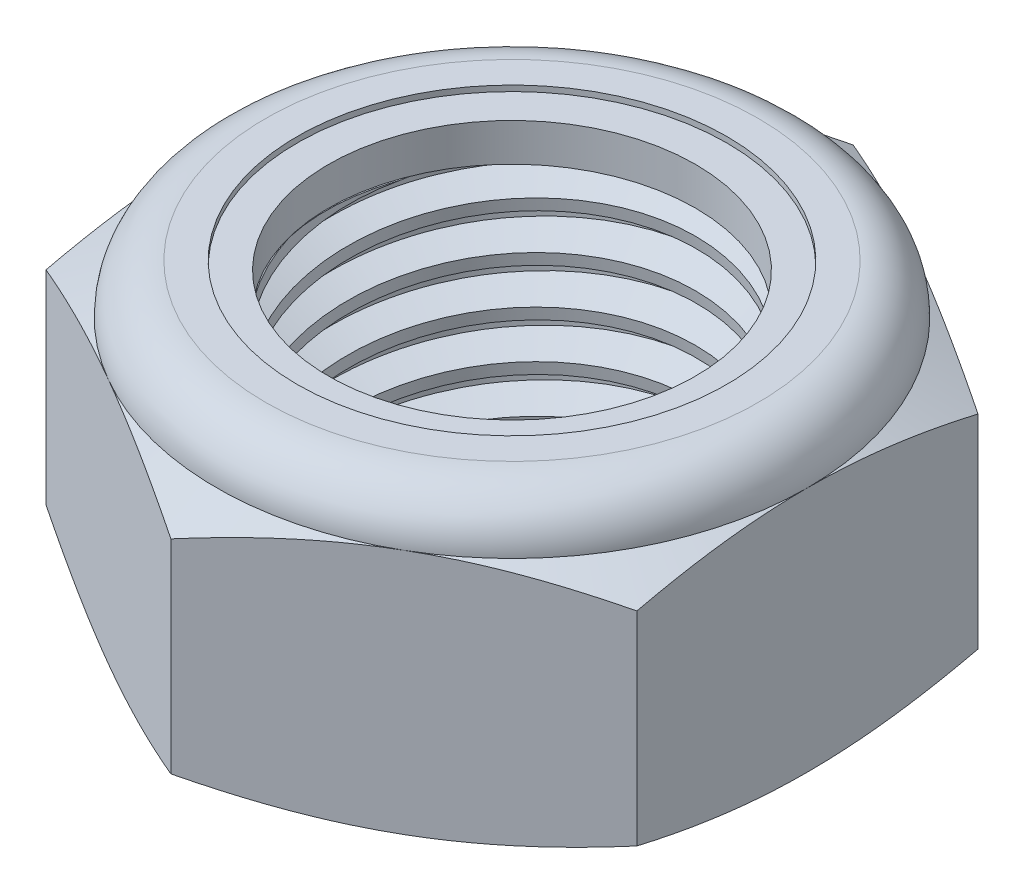
from build123d import *

# Parameters (mm, degrees)
EXTRUDE1_DEPTH      = 7.9375
SKETCH2_W           = 5.5499
SKETCH2_H           = 7.9375
LPATTERN1_COUNT     = 6
LPATTERN1_PITCH     = 1.27
LPATTERN1_COL_COUNT = 2
LPATTERN1_COL_PITCH = 1.27


with BuildPart() as part:
    # Sketch1 → Extrude1 (new body)
    with BuildSketch(Plane(origin=(0, 0, 0), x_dir=(1, 0, 0), z_dir=(0, 1, 0))):
        Polygon((0, 9.165435523), (-7.9375, 4.582717762), (-7.9375, -4.582717762), (0, -9.165435523), (7.9375, -4.582717762), (7.9375, 4.582717762), align=None)
    extrude(amount=EXTRUDE1_DEPTH)

    # Sketch4 → Cut-Revolve2 (revolve, cut)
    with BuildSketch(Plane(origin=(0, 0, 0), x_dir=(0, 0, -1), z_dir=(1, 0, 0))):
        Polygon((0, 7.9375), (5.5499, 7.9375), (4.930108683, 7.648486563), (4.930108683, 0.289013437), (5.5499, 0), (0, 0), align=None)
    revolve(axis=Axis((0, 7.9375, 0), (0, 1, 0)), mode=Mode.SUBTRACT)


with BuildPart() as body_2:
    # Sketch2 → Revolve1 (revolve)
    with BuildSketch(Plane(origin=(0, 0, 0), x_dir=(0, 0, -1), z_dir=(1, 0, 0))):
        with Locations((2.77495, 3.96875)):
            Rectangle(SKETCH2_W, SKETCH2_H)
    revolve(axis=Axis((0, -5.5499, 0), (0, 1, 0)))

    # Sketch3 → Cut-Revolve1 (revolve, cut)
    with BuildSketch(Plane(origin=(0, 0, 0), x_dir=(0, 0, -1), z_dir=(1, 0, 0))):
        Polygon((5.567945879, 7.779779016), (5.694267033, 6.675732129), (4.966200442, 6.99189364), (4.930108683, 7.307335608), align=None)
    cut_revolve1 = revolve(axis=Axis((0, 7.9375, 0.154924003), (0, -0.993518008, -0.113674829)), mode=Mode.SUBTRACT)

    # LPattern1: Cut-Revolve1 ×6
    with Locations(*[(0, -i * LPATTERN1_PITCH, 0) for i in range(1, LPATTERN1_COUNT)]):
        add(cut_revolve1, mode=Mode.SUBTRACT)

    # LPattern1 col: Cut-Revolve1 ×2
    with Locations(*[(0, i * LPATTERN1_COL_PITCH, 0) for i in range(1, LPATTERN1_COL_COUNT)]):
        add(cut_revolve1, mode=Mode.SUBTRACT)


with BuildPart() as part_1:
    add(part.part)

    # Combine1: cut body 2
    add(body_2.part, mode=Mode.SUBTRACT)

    # Sketch5 → Cut-Revolve3 (revolve, cut)
    with BuildSketch(Plane(origin=(0, 0, 0), x_dir=(0, 0, -1), z_dir=(1, 0, 0))):
        with BuildLine():
            Line((0, 0), (7.9375, 0))
            Line((7.9375, 0), (9.165435523, 0.572595738))
            Line((9.165435523, 0.572595738), (9.165435523, 6.041987595))
            Line((9.165435523, 6.041987595), (7.9375, 6.614583333))
            ThreePointArc((7.9375, 6.614583333), (7.550026679, 7.550026679), (6.614583333, 7.9375))
            Line((6.614583333, 7.9375), (6.614583333, 9.2075))
            Line((6.614583333, 9.2075), (10.435435523, 9.2075))
            Line((10.435435523, 9.2075), (10.435435523, -1.27))
            Line((10.435435523, -1.27), (0, -1.27))
            Line((0, -1.27), (0, 0))
        make_face()
    revolve(axis=Axis((0, 0, 0), (0, 1, 0)), mode=Mode.SUBTRACT)

    # Sketch6 → Cut-Revolve4 (revolve, cut)
    with BuildSketch(Plane(origin=(0, 0, 0), x_dir=(0, 0, -1), z_dir=(1, 0, 0))):
        with BuildLine():
            Line((0, 6.614583333), (7.7851, 6.614583333))
            ThreePointArc((7.7851, 6.614583333), (7.442263606, 7.442263606), (6.614583333, 7.7851))
            Line((6.614583333, 7.7851), (5.772346008, 7.7851))
            Line((5.772346008, 7.7851), (5.772346008, 9.2075))
            Line((5.772346008, 9.2075), (0, 9.2075))
            Line((0, 9.2075), (0, 6.614583333))
        make_face()
    revolve(axis=Axis((0, 9.2075, 0), (0, 1, 0)), mode=Mode.SUBTRACT)


with BuildPart() as body_2_2:
    # Sketch7 → Revolve2 (revolve)
    with BuildSketch(Plane(origin=(0, 0, 0), x_dir=(0, 0, -1), z_dir=(1, 0, 0))):
        with BuildLine():
            Line((4.930108683, 6.690783333), (7.706243778, 6.690783333))
            ThreePointArc((7.706243778, 6.690783333), (7.360955237, 7.4148695), (6.614583333, 7.7089))
            Line((6.614583333, 7.7089), (4.930108683, 7.7089))
            Line((4.930108683, 7.7089), (4.930108683, 6.690783333))
        make_face()
    revolve(axis=Axis((0, 6.690783333, 0), (0, 1, 0)))


solid = Compound([part_1.part, body_2_2.part])
